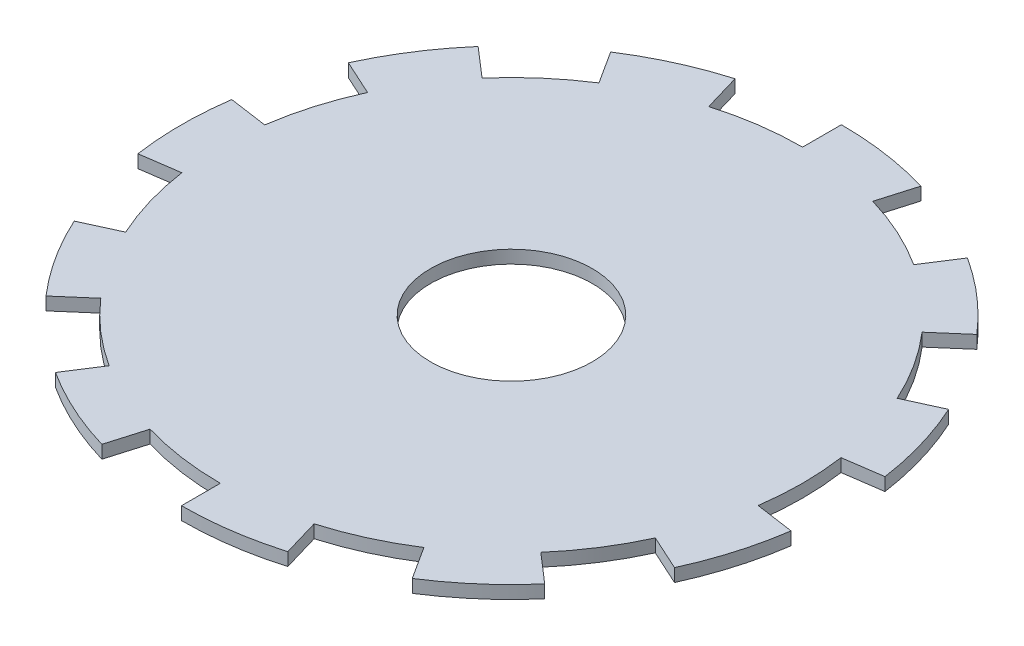
from build123d import *

# Parameters (mm, degrees)
SKETCH1_R                 = 45
BOSS_EXTRUDE1_DEPTH       = 2
BOSS_EXTRUDE2_DEPTH       = 2
CIRPATTERN1_COUNT         = 11
CIRPATTERN1_COPY_1_DEPTH  = 2
CIRPATTERN1_COPY_2_DEPTH  = 2
CIRPATTERN1_COPY_3_DEPTH  = 2
CIRPATTERN1_COPY_4_DEPTH  = 2
CIRPATTERN1_COPY_5_DEPTH  = 2
CIRPATTERN1_COPY_6_DEPTH  = 2
CIRPATTERN1_COPY_7_DEPTH  = 2
CIRPATTERN1_COPY_8_DEPTH  = 2
CIRPATTERN1_COPY_9_DEPTH  = 2
CIRPATTERN1_COPY_10_DEPTH = 2
SKETCH3_R                 = 12.5
CUT_EXTRUDE1_DEPTH        = 2


with BuildPart() as part:
    # Sketch1 → Boss-Extrude1 (new body)
    with BuildSketch(Plane(origin=(0, 0, 0), x_dir=(1, 0, 0), z_dir=(0, 1, 0))):
        Circle(SKETCH1_R)
    extrude(amount=BOSS_EXTRUDE1_DEPTH)

    # Sketch2 → Boss-Extrude2 (add)
    with BuildSketch(Plane(origin=(0, 0, 0), x_dir=(1, 0, 0), z_dir=(0, 1, 0))):
        with BuildLine():
            Line((0, 0), (-51, 0))
            ThreePointArc((-51, 0), (-50.870115566, -3.637491206), (-50.481123832, -7.256454825))
            Line((-50.481123832, -7.256454825), (0, 0))
        make_face()
    boss_extrude2 = extrude(amount=BOSS_EXTRUDE2_DEPTH)

    # Mirror1: Boss-Extrude2 across plane
    add(boss_extrude2.mirror(Plane.XY))

    # CirPattern1: Boss-Extrude2 ×11 about axis
    cirpattern1_axis = Axis((0, 0, 0), (0, 1, 0))
    for i in range(1, CIRPATTERN1_COUNT):
        add(boss_extrude2.rotate(cirpattern1_axis, i * 360 / CIRPATTERN1_COUNT))

    # CirPattern1 copy 1 sketch → CirPattern1 copy 1 (add)
    with BuildSketch(Plane(origin=(0, 0, 0), x_dir=(0.841253533, 0, -0.540640817), z_dir=(0, 1, 0))):
        with BuildLine():
            Line((0, 0), (-51, 0))
            ThreePointArc((-51, 0), (-50.870115566, 3.637491206), (-50.481123832, 7.256454825))
            Line((-50.481123832, 7.256454825), (0, 0))
        make_face()
    extrude(amount=CIRPATTERN1_COPY_1_DEPTH)

    # CirPattern1 copy 2 sketch → CirPattern1 copy 2 (add)
    with BuildSketch(Plane(origin=(0, 0, 0), x_dir=(0.415415013, 0, -0.909631995), z_dir=(0, 1, 0))):
        with BuildLine():
            Line((0, 0), (-51, 0))
            ThreePointArc((-51, 0), (-50.870115566, 3.637491206), (-50.481123832, 7.256454825))
            Line((-50.481123832, 7.256454825), (0, 0))
        make_face()
    extrude(amount=CIRPATTERN1_COPY_2_DEPTH)

    # CirPattern1 copy 3 sketch → CirPattern1 copy 3 (add)
    with BuildSketch(Plane(origin=(0, 0, 0), x_dir=(-0.142314838, 0, -0.989821442), z_dir=(0, 1, 0))):
        with BuildLine():
            Line((0, 0), (-51, 0))
            ThreePointArc((-51, 0), (-50.870115566, 3.637491206), (-50.481123832, 7.256454825))
            Line((-50.481123832, 7.256454825), (0, 0))
        make_face()
    extrude(amount=CIRPATTERN1_COPY_3_DEPTH)

    # CirPattern1 copy 4 sketch → CirPattern1 copy 4 (add)
    with BuildSketch(Plane(origin=(0, 0, 0), x_dir=(-0.654860734, 0, -0.755749574), z_dir=(0, 1, 0))):
        with BuildLine():
            Line((0, 0), (-51, 0))
            ThreePointArc((-51, 0), (-50.870115566, 3.637491206), (-50.481123832, 7.256454825))
            Line((-50.481123832, 7.256454825), (0, 0))
        make_face()
    extrude(amount=CIRPATTERN1_COPY_4_DEPTH)

    # CirPattern1 copy 5 sketch → CirPattern1 copy 5 (add)
    with BuildSketch(Plane(origin=(0, 0, 0), x_dir=(-0.959492974, 0, -0.281732557), z_dir=(0, 1, 0))):
        with BuildLine():
            Line((0, 0), (-51, 0))
            ThreePointArc((-51, 0), (-50.870115566, 3.637491206), (-50.481123832, 7.256454825))
            Line((-50.481123832, 7.256454825), (0, 0))
        make_face()
    extrude(amount=CIRPATTERN1_COPY_5_DEPTH)

    # CirPattern1 copy 6 sketch → CirPattern1 copy 6 (add)
    with BuildSketch(Plane(origin=(0, 0, 0), x_dir=(-0.959492974, 0, 0.281732557), z_dir=(0, 1, 0))):
        with BuildLine():
            Line((0, 0), (-51, 0))
            ThreePointArc((-51, 0), (-50.870115566, 3.637491206), (-50.481123832, 7.256454825))
            Line((-50.481123832, 7.256454825), (0, 0))
        make_face()
    extrude(amount=CIRPATTERN1_COPY_6_DEPTH)

    # CirPattern1 copy 7 sketch → CirPattern1 copy 7 (add)
    with BuildSketch(Plane(origin=(0, 0, 0), x_dir=(-0.654860734, 0, 0.755749574), z_dir=(0, 1, 0))):
        with BuildLine():
            Line((0, 0), (-51, 0))
            ThreePointArc((-51, 0), (-50.870115566, 3.637491206), (-50.481123832, 7.256454825))
            Line((-50.481123832, 7.256454825), (0, 0))
        make_face()
    extrude(amount=CIRPATTERN1_COPY_7_DEPTH)

    # CirPattern1 copy 8 sketch → CirPattern1 copy 8 (add)
    with BuildSketch(Plane(origin=(0, 0, 0), x_dir=(-0.142314838, 0, 0.989821442), z_dir=(0, 1, 0))):
        with BuildLine():
            Line((0, 0), (-51, 0))
            ThreePointArc((-51, 0), (-50.870115566, 3.637491206), (-50.481123832, 7.256454825))
            Line((-50.481123832, 7.256454825), (0, 0))
        make_face()
    extrude(amount=CIRPATTERN1_COPY_8_DEPTH)

    # CirPattern1 copy 9 sketch → CirPattern1 copy 9 (add)
    with BuildSketch(Plane(origin=(0, 0, 0), x_dir=(0.415415013, 0, 0.909631995), z_dir=(0, 1, 0))):
        with BuildLine():
            Line((0, 0), (-51, 0))
            ThreePointArc((-51, 0), (-50.870115566, 3.637491206), (-50.481123832, 7.256454825))
            Line((-50.481123832, 7.256454825), (0, 0))
        make_face()
    extrude(amount=CIRPATTERN1_COPY_9_DEPTH)

    # CirPattern1 copy 10 sketch → CirPattern1 copy 10 (add)
    with BuildSketch(Plane(origin=(0, 0, 0), x_dir=(0.841253533, 0, 0.540640817), z_dir=(0, 1, 0))):
        with BuildLine():
            Line((0, 0), (-51, 0))
            ThreePointArc((-51, 0), (-50.870115566, 3.637491206), (-50.481123832, 7.256454825))
            Line((-50.481123832, 7.256454825), (0, 0))
        make_face()
    extrude(amount=CIRPATTERN1_COPY_10_DEPTH)

    # Sketch3 → Cut-Extrude1 (cut)
    with BuildSketch(Plane(origin=(0, 2, 0), x_dir=(1, 0, 0), z_dir=(0, 1, 0))):
        Circle(SKETCH3_R)
    extrude(amount=-CUT_EXTRUDE1_DEPTH, mode=Mode.SUBTRACT)


solid = part.part
